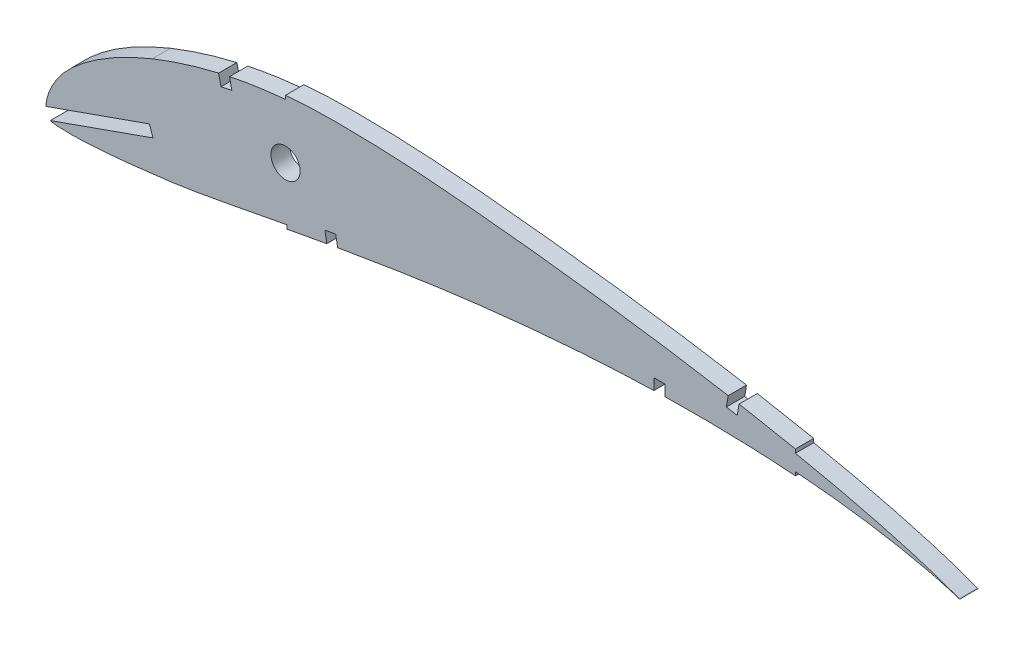
from build123d import *

# Parameters (mm, degrees)
SKETCH1_R           = 3.999999999
BOSS_EXTRUDE2_DEPTH = 5


with BuildPart() as part:
    # Sketch1 → Boss-Extrude2 (new body)
    with BuildSketch(Plane.XY):
        with BuildLine():
            Line((-15.274923413, 29.833619039), (-15.274923413, 32.833619039))
            Line((-15.274923413, 32.833619039), (-18.274923413, 32.833619039))
            Line((-18.274923413, 32.833619039), (-18.274923413, 29.764253579))
            add(Edge.make_bspline(
                [(-66.252426936, 26.136064153), (-65.99153802, 26.167490518), (-61.550040243, 26.699622457), (-52.874715524, 27.642842037), (-40.202279044, 28.718895324), (-28.651441859, 29.412825252), (-21.337967835, 29.682959943), (-18.274923413, 29.764253579)],
                knots=[0.732012022, 0.732012022, 0.732012022, 0.732012022, 0.733426689, 0.756094118, 0.778988554, 0.801889683, 0.81838539, 0.81838539, 0.81838539, 0.81838539], degree=3))
            add(Edge.make_bspline(
                [(-104.796120847, 20.355168115), (-103.559333031, 20.572720582), (-98.520663765, 21.448820944), (-89.516418694, 22.932693275), (-77.905936271, 24.657488266), (-70.092430975, 25.673501889), (-66.252426936, 26.136064153)],
                knots=[0.662061604, 0.662061604, 0.662061604, 0.662061604, 0.668822257, 0.689594964, 0.711189651, 0.732012022, 0.732012022, 0.732012022, 0.732012022], degree=3))
            Line((-104.796120847, 20.355168115), (-105.316612447, 23.314167741))
            Line((-105.316612447, 23.314167741), (-108.269681049, 22.785598135))
            Line((-108.269681049, 22.785598135), (-107.741111444, 19.832529532))
            add(Edge.make_bspline(
                [(-118.70797288, 17.816784281), (-116.449296053, 18.24080163), (-112.795049314, 18.920221392), (-109.137653616, 19.582562517), (-107.741111444, 19.832529532)],
                knots=[0.636683753, 0.636683753, 0.636683753, 0.636683753, 0.649056124, 0.656694096, 0.656694096, 0.656694096, 0.656694096], degree=3))
            Line((-118.70797288, 17.816784281), (-118.70797288, 18.846655309))
            add(Edge.make_bspline(
                [(-183.394556944, 11.182987133), (-183.269597768, 11.136643498), (-182.979327212, 11.047444159), (-182.357072613, 10.91794176), (-181.480978355, 10.844493332), (-180.310934344, 10.800500045), (-178.773368721, 10.744182309), (-176.863824927, 10.725976619), (-174.562346174, 10.805796173), (-172.239703955, 10.932232791), (-169.146965898, 11.131368159), (-165.284504809, 11.447886607), (-160.649899412, 11.910670397), (-156.019974465, 12.434658225), (-151.397129438, 13.012896286), (-145.26003141, 13.893026363), (-137.616562363, 15.236357693), (-128.260301851, 17.042564162), (-121.953662416, 18.237432565), (-118.70797288, 18.846655309)],
                knots=[0.518863676, 0.518863676, 0.518863676, 0.518863676, 0.519756125, 0.520804075, 0.522899974, 0.524995873, 0.527091772, 0.531283569, 0.535475367, 0.539667165, 0.543858963, 0.552242559, 0.560626155, 0.569009751, 0.577393346, 0.585776942, 0.602544134, 0.619311326, 0.637085452, 0.637085452, 0.637085452, 0.637085452], degree=3))
            Line((-183.394556944, 11.182987133), (-155.295131064, 21.116274472))
            Line((-155.295131064, 21.116274472), (-156.295009381, 23.944744615))
            Line((-156.295009381, 23.944744615), (-184.579710813, 13.945961444))
            add(Edge.make_bspline(
                [(-155.515782717, 39.759167392), (-158.198801988, 38.674937943), (-163.647725294, 36.211238779), (-170.146091995, 32.449410331), (-175.089444119, 28.817226184), (-178.524066381, 25.800644684), (-180.954655773, 22.934036286), (-182.562392143, 20.398985473), (-183.559377406, 18.410224133), (-184.165249843, 16.676872754), (-184.477069616, 15.262053142), (-184.565495729, 14.472335947), (-184.578634412, 14.038444976), (-184.579710813, 13.945961444)],
                knots=[0.435917337, 0.435917337, 0.435917337, 0.435917337, 0.451639409, 0.468406601, 0.476790197, 0.485173793, 0.493557388, 0.497749186, 0.501940984, 0.506132782, 0.508228681, 0.51032458, 0.510893724, 0.510893724, 0.510893724, 0.510893724], degree=3))
            add(Edge.make_bspline(
                [(-137.360746756, 45.452039662), (-140.347626388, 44.756774519), (-146.297136186, 43.145936866), (-152.294225784, 41.051484901), (-155.337429936, 39.83124117), (-155.515782717, 39.759167392)],
                knots=[0.401467303, 0.401467303, 0.401467303, 0.401467303, 0.418105026, 0.434872218, 0.435917337, 0.435917337, 0.435917337, 0.435917337], degree=3))
            Line((-137.360746756, 45.452039662), (-136.68868811, 42.564855828))
            Line((-136.68868811, 42.564855828), (-133.751456289, 43.175322491))
            Line((-133.751456289, 43.175322491), (-134.361922941, 46.112554263))
            add(Edge.make_bspline(
                [(-119.03943959, 48.367699671), (-122.101427551, 48.095199158), (-127.234989348, 47.466204387), (-132.315203048, 46.53793923), (-134.361922941, 46.112554263)],
                knots=[0.367899246, 0.367899246, 0.367899246, 0.367899246, 0.384570643, 0.395913549, 0.395913549, 0.395913549, 0.395913549], degree=3))
            Line((-119.03943959, 48.367699671), (-119.03943959, 49.362753806))
            add(Edge.make_bspline(
                [(2.083438055, 38.756140327), (-0.72889412, 39.244043897), (-6.696332714, 40.243753549), (-15.89790578, 41.668993742), (-25.558864032, 43.056561005), (-35.361070129, 44.355773078), (-45.233526647, 45.562472552), (-55.097310785, 46.685203514), (-64.8707651, 47.695636562), (-74.474266757, 48.574860292), (-83.840272575, 49.273387192), (-92.915280488, 49.753884046), (-101.648803262, 49.961384976), (-109.996100301, 49.939297857), (-115.749241876, 49.643362388), (-118.71147616, 49.391814724), (-119.03943959, 49.362753806)],
                knots=[1.14918421, 1.14918421, 1.14918421, 1.14918421, 1.164550917, 1.181757895, 1.199311955, 1.217095072, 1.234990228, 1.252856883, 1.270540594, 1.287886779, 1.304773438, 1.321101419, 1.336806063, 1.351800033, 1.366031063, 1.367803451, 1.367803451, 1.367803451, 1.367803451], degree=3))
            Line((2.083438055, 38.756140327), (1.570636408, 35.800292785))
            Line((1.570636408, 35.800292785), (4.526483923, 35.287491143))
            Line((4.526483923, 35.287491143), (5.050453634, 38.235119732))
            add(Edge.make_bspline(
                [(20.460560403, 35.302628948), (20.394409373, 35.316097767), (17.49241378, 35.906446136), (12.360542854, 36.910434115), (7.283049441, 37.838254067), (5.050453634, 38.235119732)],
                knots=[1.115627198, 1.115627198, 1.115627198, 1.115627198, 1.115990637, 1.131570422, 1.143778302, 1.143778302, 1.143778302, 1.143778302], degree=3))
            Line((20.460560403, 35.302628948), (20.460560403, 34.282075586))
            add(Edge.make_bspline(
                [(65.275097468, 22.239991987), (61.679361096, 23.640965601), (54.353421886, 26.066791161), (43.149959551, 29.165035882), (31.890085438, 31.87342955), (24.331612619, 33.492515647), (20.531307928, 34.267655777), (20.487084066, 34.276670707), (20.460560403, 34.282075586)],
                knots=[1.031789372, 1.031789372, 1.031789372, 1.031789372, 1.052705995, 1.073622619, 1.094539242, 1.115212513, 1.115309854, 1.115455866, 1.115455866, 1.115455866, 1.115455866], degree=3))
            Line((65.275097468, 22.239991987), (65.414953329, 22.185501237))
            Line((65.414953329, 22.185501237), (65.370311306, 22.197604251))
            Line((65.370311306, 22.197604251), (65.30990973, 22.216811525))
            Line((65.30990973, 22.216811525), (65.168978604, 22.261626625))
            add(Edge.make_bspline(
                [(20.460560403, 29.92806979), (24.272131516, 29.638464904), (31.828857812, 28.924140294), (43.093807963, 27.389001087), (54.218645522, 25.284722166), (61.564813063, 23.407725759), (65.168978604, 22.261626625)],
                knots=[0.887815213, 0.887815213, 0.887815213, 0.887815213, 0.908324161, 0.928537761, 0.948751361, 0.96896496, 0.96896496, 0.96896496, 0.96896496], degree=3))
            Line((20.460560403, 29.92806979), (20.460560403, 28.918286698))
            add(Edge.make_bspline(
                [(-15.274923413, 29.833619039), (-15.127043667, 29.836529068), (-10.8514258, 29.918473039), (-2.571900305, 29.953998423), (9.197726912, 29.642084048), (16.829562085, 29.195008503), (20.460560403, 28.918286698)],
                knots=[0.823770335, 0.823770335, 0.823770335, 0.823770335, 0.824566598, 0.846792285, 0.868338291, 0.887942194, 0.887942194, 0.887942194, 0.887942194], degree=3))
        make_face()
        with Locations((-119.03943959, 33.331153055)):
            Circle(SKETCH1_R, mode=Mode.SUBTRACT)
    extrude(amount=BOSS_EXTRUDE2_DEPTH)


solid = part.part
